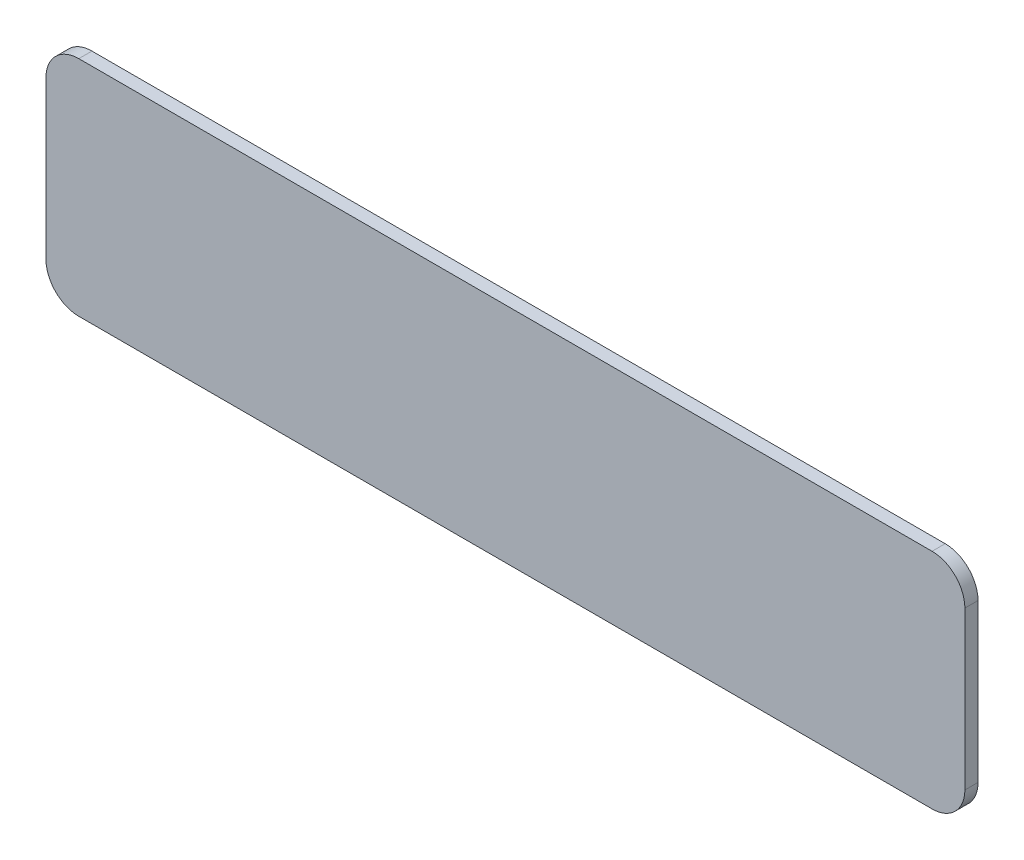
from build123d import *

# Parameters (mm, degrees)
BOSS_EXTRUDE1_DEPTH = 2


with BuildPart() as part:
    # Sketch1 → Boss-Extrude1 (new body)
    with BuildSketch(Plane.XY):
        with BuildLine():
            Line((-65, 17), (65, 17))
            ThreePointArc((65, 17), (68.535533906, 15.535533906), (70, 12))
            Line((70, 12), (70, -12))
            ThreePointArc((70, -12), (68.535533906, -15.535533906), (65, -17))
            Line((65, -17), (-65, -17))
            ThreePointArc((-65, -17), (-68.535533906, -15.535533906), (-70, -12))
            Line((-70, -12), (-70, 12))
            ThreePointArc((-70, 12), (-68.535533906, 15.535533906), (-65, 17))
        make_face()
    extrude(amount=BOSS_EXTRUDE1_DEPTH)


solid = part.part
